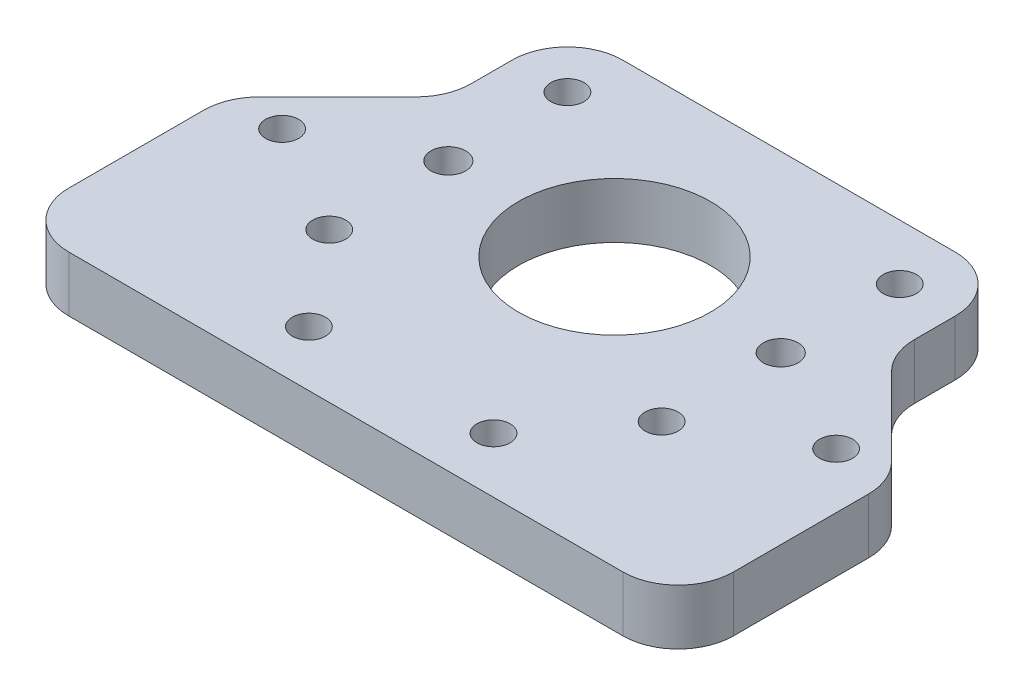
from build123d import *

# Parameters (mm, degrees)
SKETCH1_R           = 11
BOSS_EXTRUDE1_DEPTH = 6.35
SKETCH2_R           = 1.9939
CUT_EXTRUDE1_DEPTH  = 7.35
SKETCH14_R          = 1.89865
M3_TAP_DEPTH        = 7.35
SKETCH15_R          = 1.89865
M5_THROUGH_DEPTH    = 7.35
CUT_EXTRUDE2_DEPTH  = 7.35
FILLET2_R           = 6.35


with BuildPart() as part:
    # Sketch1 → Boss-Extrude1 (new body)
    with BuildSketch(Plane(origin=(0, 0, 0), x_dir=(1, 0, 0), z_dir=(0, 1, 0))):
        Polygon((0, 0), (76.2, 0), (76.2, 50.8), (38.1, 50.8), (0, 50.8), align=None)
        with Locations((38.1, 30.8)):
            Circle(SKETCH1_R, mode=Mode.SUBTRACT)
    extrude(amount=BOSS_EXTRUDE1_DEPTH)

    # Sketch2 → Cut-Extrude1 (cut, through all)
    with BuildSketch(Plane(origin=(0, 6.35, 0), x_dir=(1, 0, 0), z_dir=(0, 1, 0))):
        with Locations((19.05, 30.8)):
            Circle(SKETCH2_R)
        with Locations((57.15, 30.8)):
            Circle(SKETCH2_R)
    extrude(amount=-CUT_EXTRUDE1_DEPTH, mode=Mode.SUBTRACT)

    # Sketch14 → M3-tap (cut, through all)
    with BuildSketch(Plane.XZ):
        with Locations((57.15, -44.45)):
            Circle(SKETCH14_R)
        with Locations((19.05, -44.45)):
            Circle(SKETCH14_R)
        with Locations((19.05, -17.15)):
            Circle(SKETCH14_R)
        with Locations((57.15, -17.15)):
            Circle(SKETCH14_R)
    extrude(amount=-M3_TAP_DEPTH, mode=Mode.SUBTRACT)

    # Sketch15 → M5-through (cut, through all)
    with BuildSketch(Plane.XZ):
        with Locations((69.85, -24.45004)):
            Circle(SKETCH15_R)
        with Locations((48.683333333, -6.35)):
            Circle(SKETCH15_R)
        with Locations((27.516666667, -6.35)):
            Circle(SKETCH15_R)
        with Locations((6.35, -24.45004)):
            Circle(SKETCH15_R)
    extrude(amount=-M5_THROUGH_DEPTH, mode=Mode.SUBTRACT)

    # Sketch12 → Cut-Extrude2 (cut, through all)
    with BuildSketch(Plane(origin=(0, 6.35, 0), x_dir=(1, 0, 0), z_dir=(0, 1, 0))):
        Polygon((0, 50.8), (12.7, 50.8), (12.7, 37.15), (0, 24.45), align=None)
        Polygon((63.5, 50.8), (63.5, 37.15), (76.2, 24.45), (76.2, 50.8), align=None)
    extrude(amount=-CUT_EXTRUDE2_DEPTH, mode=Mode.SUBTRACT)

    # Fillet2
    fillet2_edges = [part.edges().sort_by_distance(p)[0] for p in [
        (0, 3.175, -24.45),
        (12.7, 3.175, -50.8),
        (12.7, 3.175, -37.15),
        (63.5, 3.175, -50.8),
        (76.2, 3.175, -24.45),
        (63.5, 3.175, -37.15),
        (76.2, 3.175, 0),
        (0, 3.175, 0),
    ]]
    fillet(fillet2_edges, radius=FILLET2_R)


solid = part.part
